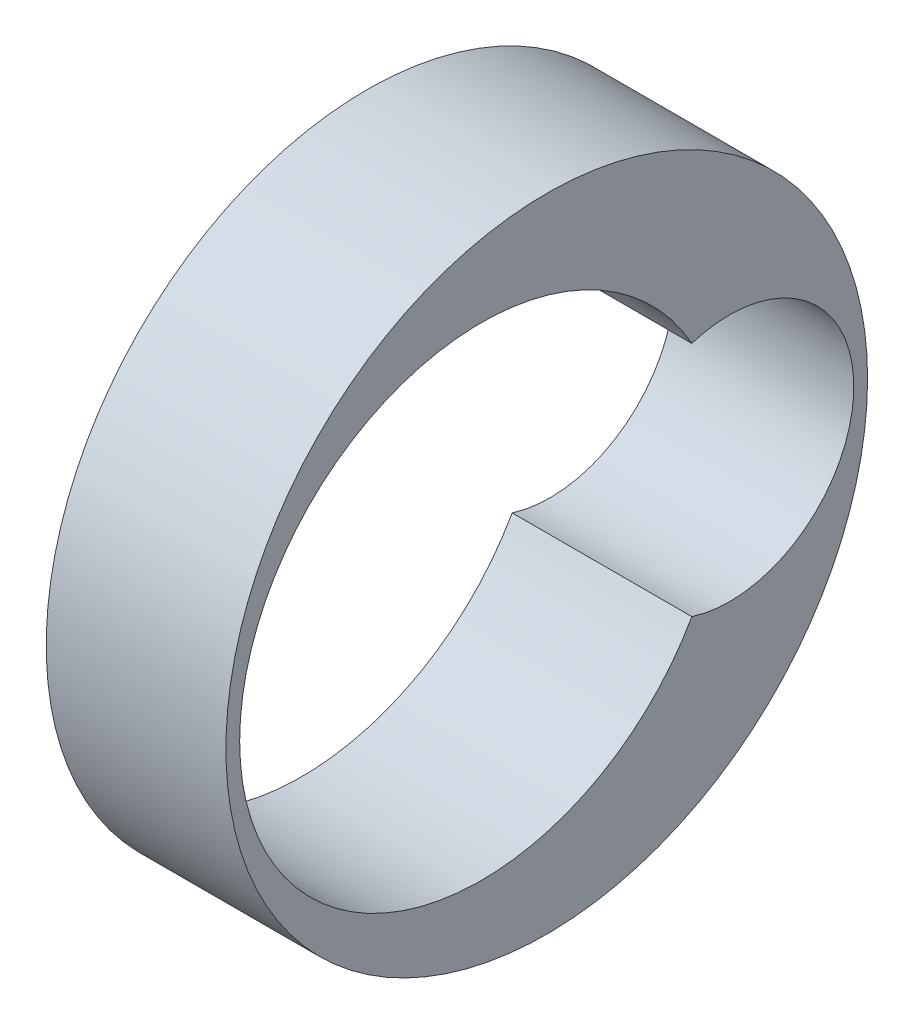
from build123d import *

# Parameters (mm, degrees)
SKETCH1_R           = 7.75
BOSS_EXTRUDE1_DEPTH = 4.34


with BuildPart() as part:
    # Sketch1 → Boss-Extrude1 (new body)
    with BuildSketch(Plane(origin=(0, 0, 0), x_dir=(0, 0, -1), z_dir=(1, 0, 0))):
        with Locations((16.196131771, -0.506129118)):
            Circle(SKETCH1_R)
        with BuildLine():
            ThreePointArc((19.700900521, 2.351653531), (8.778631771, -0.506129118), (19.700900521, -3.363911766))
            ThreePointArc((19.700900521, -3.363911766), (23.613631771, -0.506129118), (19.700900521, 2.351653531))
        make_face(mode=Mode.SUBTRACT)
    extrude(amount=BOSS_EXTRUDE1_DEPTH)


solid = part.part
